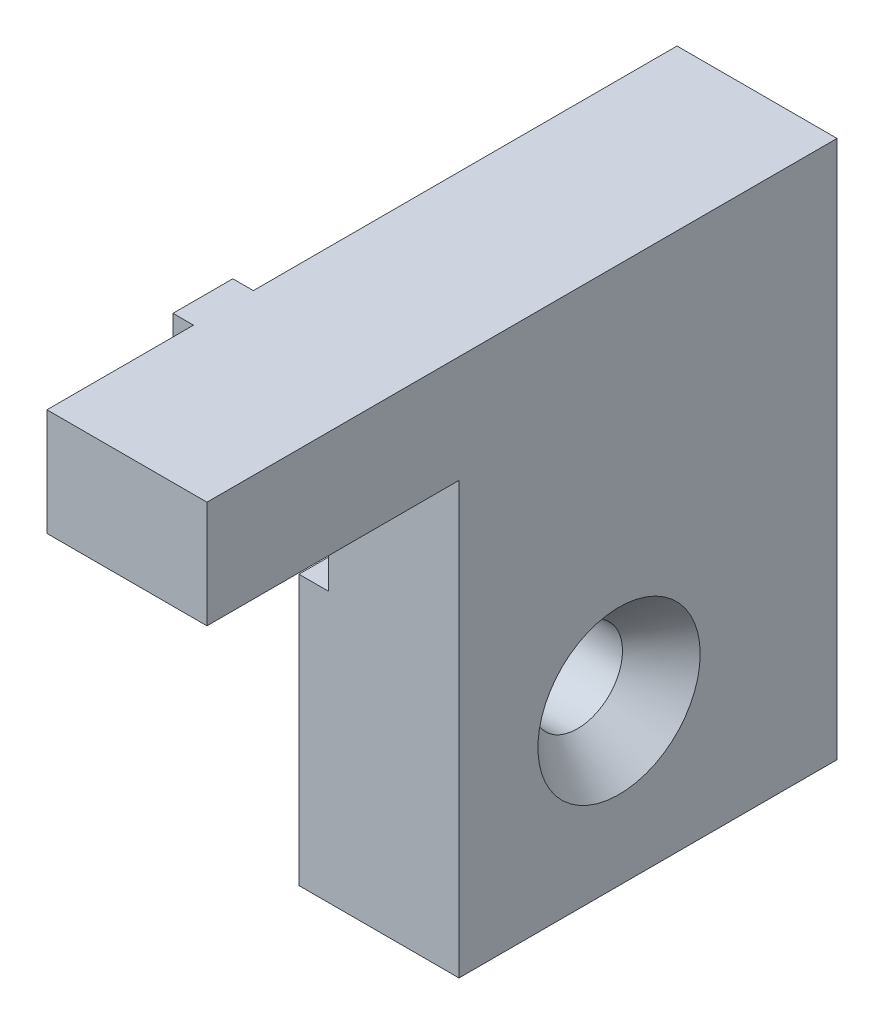
from build123d import *

# Parameters (mm, degrees)
SKETCH1_W                                        = 30
SKETCH1_H                                        = 42.7
SKETCH1_R                                        = 3.175
SKETCH1_W_2                                      = 20
SKETCH1_H_2                                      = 8.5
BOSS_EXTRUDE1_DEPTH                              = 12.7
CSK_FOR_1_4_FLAT_HEAD_MACHINE_SCREW1_D           = 7.14248
CSK_FOR_1_4_FLAT_HEAD_MACHINE_SCREW1_CSINK_D     = 12.8778
CSK_FOR_1_4_FLAT_HEAD_MACHINE_SCREW1_CSINK_ANGLE = 82
SKETCH3_W                                        = 8
SKETCH3_H                                        = 12.8
CUT_EXTRUDE1_DEPTH                               = 2.35
SKETCH4_W                                        = 4.75
SKETCH4_H                                        = 8.5
BOSS_EXTRUDE2_DEPTH                              = 1.63


with BuildPart() as part:
    # Sketch1 → Boss-Extrude1 (new body)
    with BuildSketch(Plane(origin=(0, 0, 0), x_dir=(0, 0, -1), z_dir=(1, 0, 0))):
        with Locations((15, -12.85)):
            Rectangle(SKETCH1_W, SKETCH1_H)
        with Locations((12.7, -21.5)):
            Circle(SKETCH1_R, mode=Mode.SUBTRACT)
        with Locations((-10, 4.25)):
            Rectangle(SKETCH1_W_2, SKETCH1_H_2)
    extrude(amount=BOSS_EXTRUDE1_DEPTH)

    # CSK for 1/4 Flat Head Machine Screw1 (through all)
    with Locations(Plane(origin=(12.7, -21.5, -12.7), x_dir=(0, 0, 1), z_dir=(1, 0, 0))):
        with Locations((0, 0)):
            CounterSinkHole(CSK_FOR_1_4_FLAT_HEAD_MACHINE_SCREW1_D / 2, CSK_FOR_1_4_FLAT_HEAD_MACHINE_SCREW1_CSINK_D / 2, counter_sink_angle=CSK_FOR_1_4_FLAT_HEAD_MACHINE_SCREW1_CSINK_ANGLE)

    # Sketch3 → Cut-Extrude1 (cut)
    with BuildSketch(Plane.ZY):
        with Locations((-4, -6.4)):
            Rectangle(SKETCH3_W, SKETCH3_H)
    extrude(amount=-CUT_EXTRUDE1_DEPTH, mode=Mode.SUBTRACT)

    # Sketch4 → Boss-Extrude2 (add)
    with BuildSketch(Plane.ZY):
        with Locations((5.995, 4.25)):
            Rectangle(SKETCH4_W, SKETCH4_H)
    extrude(amount=BOSS_EXTRUDE2_DEPTH)


solid = part.part
